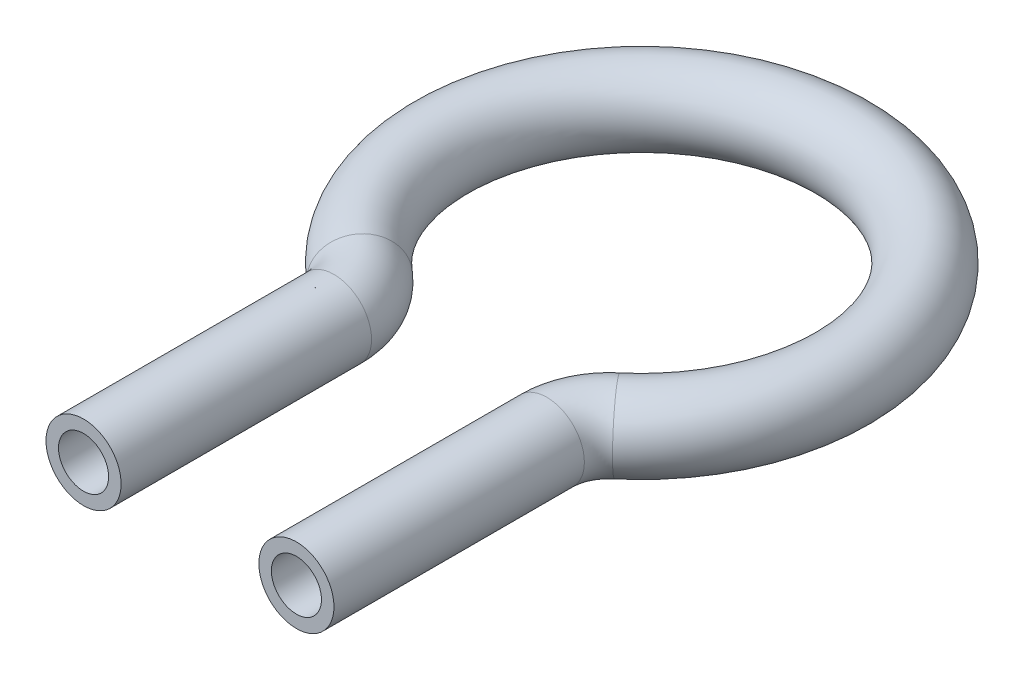
from build123d import *

# Parameters (mm, degrees)
SKETCH2_R   = 3
SKETCH2_R_2 = 2


with BuildPart() as part:
    # Sweep1: sweep along a path in Sketch1
    with BuildLine(Plane(origin=(0, 0, 0), x_dir=(1, 0, 0), z_dir=(0, 1, 0))) as sweep1_path:
        Line((8.5, -36.085707942), (8.5, -16.085707942))
        ThreePointArc((8.5, -16.085707942), (8.968365164, -13.972822305), (10.285714286, -12.25577748))
        ThreePointArc((10.285714286, -12.25577748), (0, 16), (-10.285714286, -12.25577748))
        ThreePointArc((-10.285714286, -12.25577748), (-8.968365164, -13.972822305), (-8.5, -16.085707942))
        Line((-8.5, -16.085707942), (-8.5, -36.085707942))
    # Sketch2 → Sweep1 (sweep)
    with BuildSketch(Plane(origin=(-8.5, 0, 36.085707942), x_dir=(-1, 0, 0), z_dir=(0, 0, -1))):
        Circle(SKETCH2_R)
        Circle(SKETCH2_R_2, mode=Mode.SUBTRACT)
    sweep(path=sweep1_path.line)


solid = part.part
